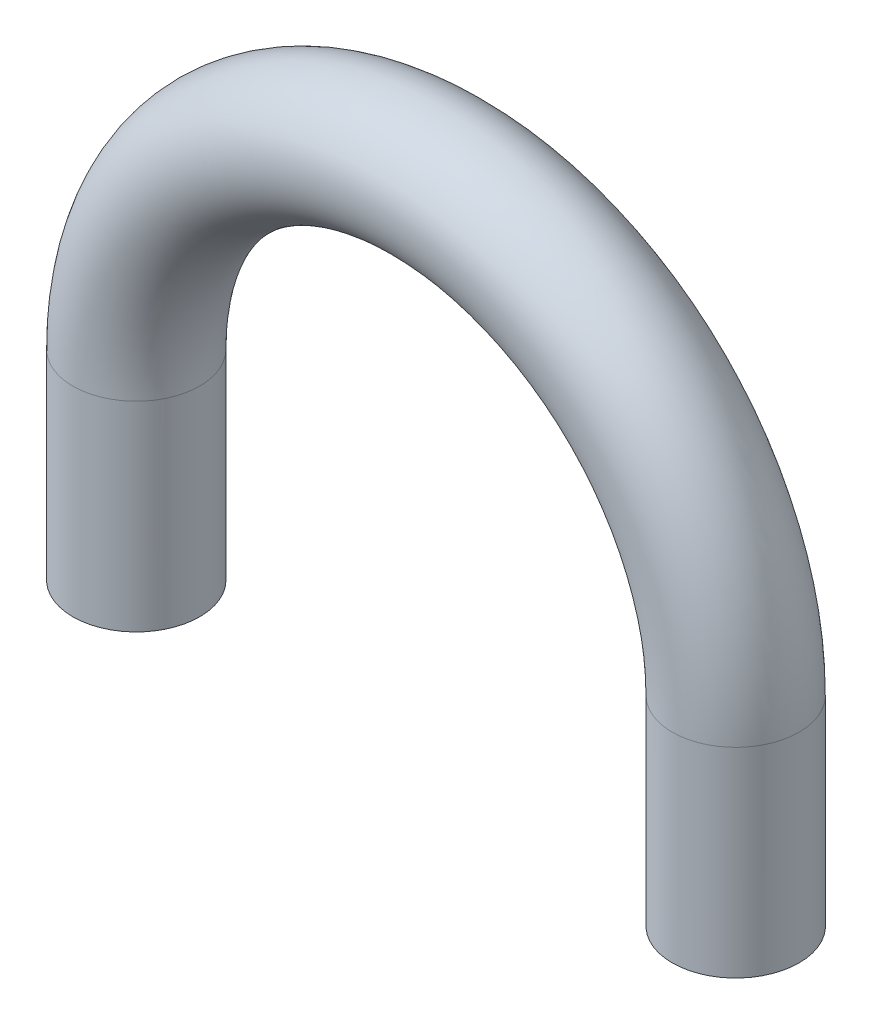
from build123d import *

# Parameters (mm, degrees)
BALAYAGE3_PROFILE_R = 3.175


with BuildPart() as part:
    # Balayage3: sweep along a path in Esquisse1
    with BuildLine(Plane.XY) as balayage3_path:
        Line((-15, -10), (-15, 0))
        ThreePointArc((-15, 0), (0, 15), (15, 0))
        Line((15, 0), (15, -10))
    # Balayage3 profile (on start of the path) → Balayage3 (sweep)
    with BuildSketch(Plane(origin=(-15, -10, 0), x_dir=(0, 0, 1), z_dir=(0, 1, 0))):
        Circle(BALAYAGE3_PROFILE_R)
    sweep(path=balayage3_path.line)


solid = part.part
